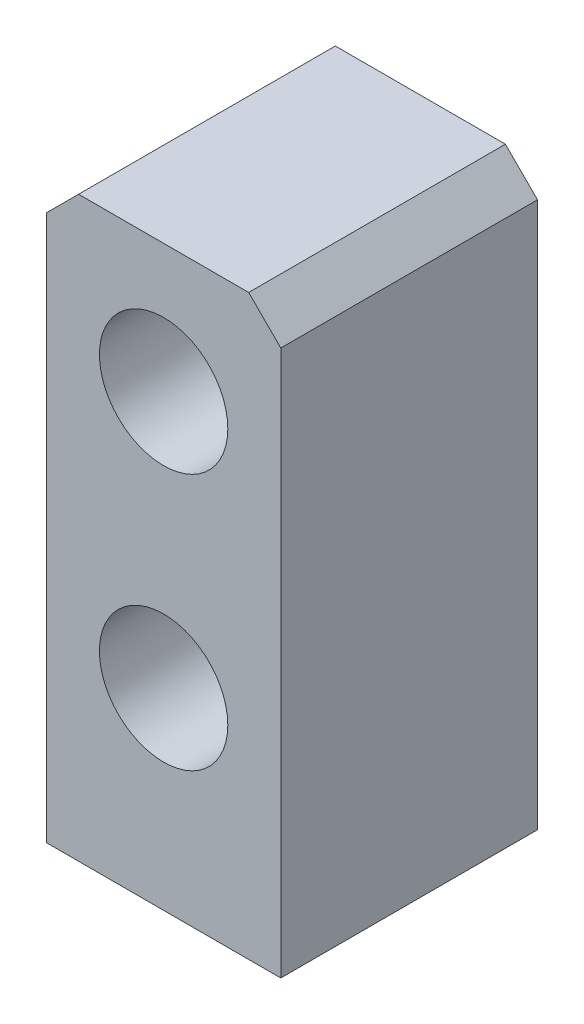
from build123d import *

# Parameters (mm, degrees)
SALIENTE_EXTRUIR1_DEPTH = 40
CROQUIS2_R              = 10
CORTAR_EXTRUIR1_DEPTH   = 40


with BuildPart() as part:
    # Croquis1 → Saliente-Extruir1 (new body)
    with BuildSketch(Plane.XY):
        Polygon((-18.25, 40), (-13.25, 45), (13.25, 45), (18.25, 40), (18.25, -45), (-18.25, -45), align=None)
    extrude(amount=SALIENTE_EXTRUIR1_DEPTH)

    # Croquis2 → Cortar-Extruir1 (cut)
    with BuildSketch(Plane.XY.offset(40)):
        with Locations((0, 25)):
            Circle(CROQUIS2_R)
        with Locations((0, -15)):
            Circle(CROQUIS2_R)
    extrude(amount=-CORTAR_EXTRUIR1_DEPTH, mode=Mode.SUBTRACT)


solid = part.part
